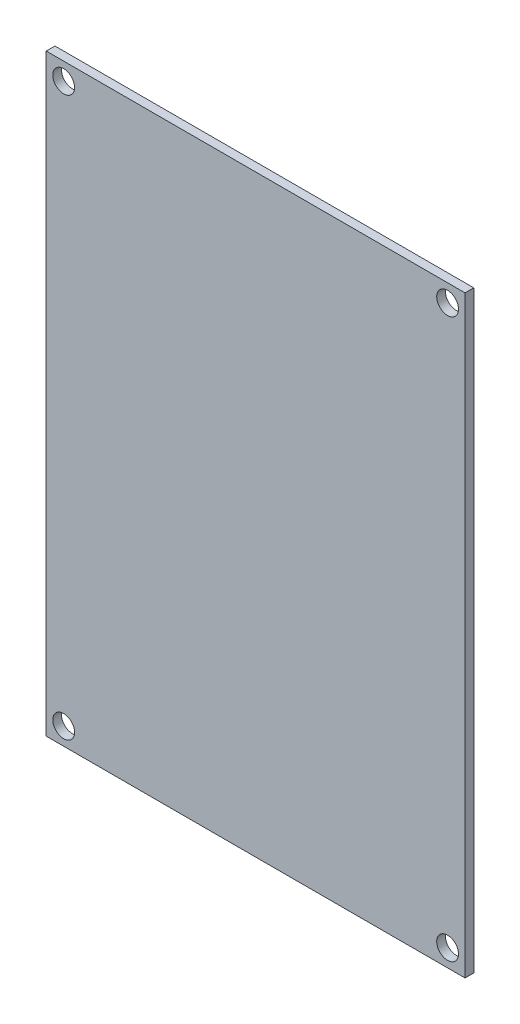
from build123d import *

# Parameters (mm, degrees)
ESQUISSE1_W             = 480
ESQUISSE1_H             = 680
BOSS_EXTRU_1_DEPTH      = 10
ESQUISSE2_R             = 12.5
ENL_V_MAT_EXTRU_1_DEPTH = 10


with BuildPart() as part:
    # Esquisse1 → Boss.-Extru.1 (new body)
    with BuildSketch(Plane.XY):
        with Locations((-50, 0)):
            Rectangle(ESQUISSE1_W, ESQUISSE1_H)
    extrude(amount=BOSS_EXTRU_1_DEPTH)

    # Esquisse2 → Enlèv. mat.-Extru.1 (cut)
    with BuildSketch(Plane.XY.offset(10)):
        with Locations((170, 320)):
            Circle(ESQUISSE2_R)
        with Locations((-270, 320)):
            Circle(ESQUISSE2_R)
        with Locations((-270, -320)):
            Circle(ESQUISSE2_R)
        with Locations((170, -320)):
            Circle(ESQUISSE2_R)
    extrude(amount=-ENL_V_MAT_EXTRU_1_DEPTH, mode=Mode.SUBTRACT)


solid = part.part
